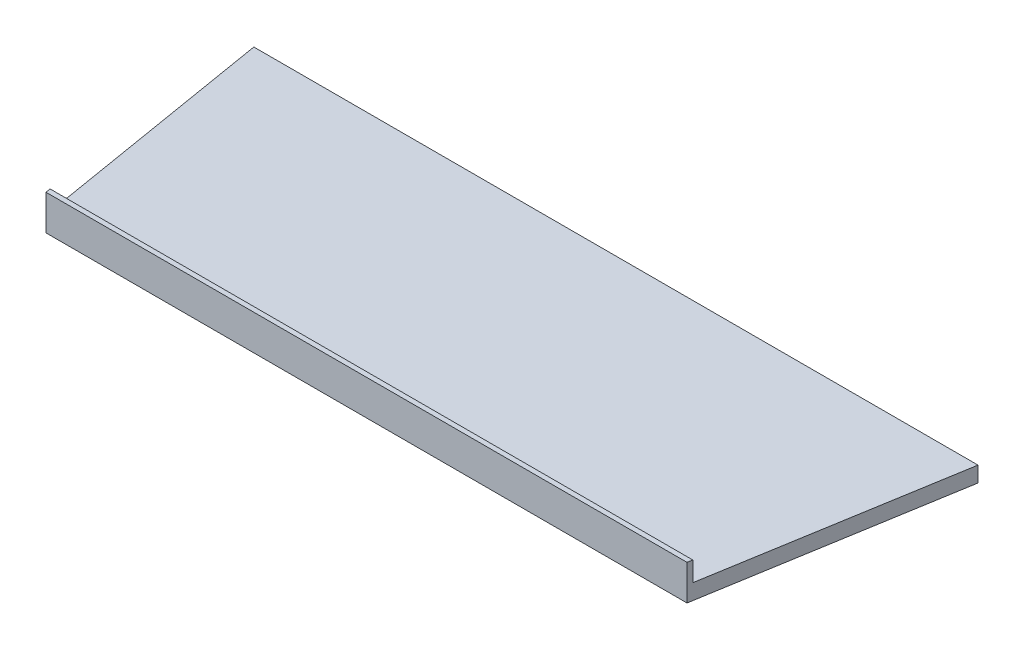
from build123d import *

# Parameters (mm, degrees)
BOSS_EXTRUDE1_DEPTH = 10
BOSS_EXTRUDE2_DEPTH = 12.7


with BuildPart() as part:
    # Sketch1 → Boss-Extrude1 (new body)
    with BuildSketch(Plane(origin=(0, 0, 0), x_dir=(1, 0, 0), z_dir=(0, 1, 0))):
        Polygon((-248.535594609, 74.707564465), (-221.743927942, -86.042435535), (191.397738725, -86.042435535), (218.189405391, 74.707564465), align=None)
    extrude(amount=BOSS_EXTRUDE1_DEPTH)

    # Sketch2 → Boss-Extrude2 (add)
    with BuildSketch(Plane(origin=(0, 10, 0), x_dir=(1, 0, 0), z_dir=(0, 1, 0))):
        Polygon((-221.743927942, -86.042435535), (191.397738725, -86.042435535), (191.926905391, -82.867435535), (-222.273094609, -82.867435535), align=None)
    extrude(amount=BOSS_EXTRUDE2_DEPTH)


solid = part.part
